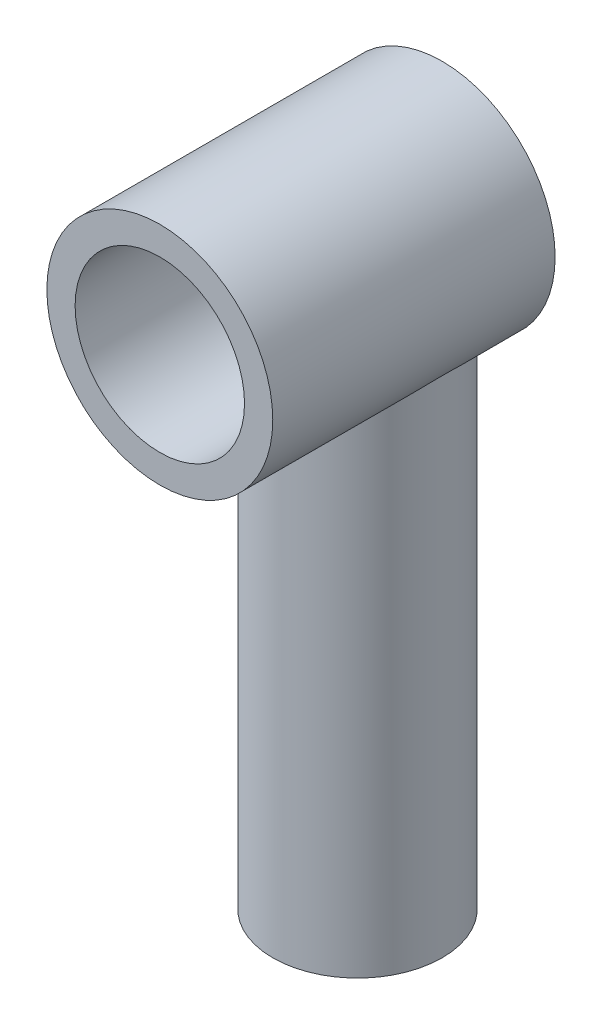
from build123d import *

# Parameters (mm, degrees)
ESQUISSE1_R             = 4
BOSS_EXTRU_1_DEPTH      = 8
BOSS_EXTRU_1_DEPTH_BACK = 2
ESQUISSE4_R             = 2
ENL_V_MAT_EXTRU_2_DEPTH = 18
BOSS_EXTRU_2_START      = -2.5
ESQUISSE3_R             = 3
ESQUISSE3_R_2           = 2
BOSS_EXTRU_2_DEPTH      = 1
BOSS_EXTRU_2_DEPTH_BACK = 18
ESQUISSE2_R             = 3
ENL_V_MAT_EXTRU_3_DEPTH = 9


with BuildPart() as part:
    # Esquisse1 → Boss.-Extru.1 (new body, two sides)
    with BuildSketch(Plane.XY) as boss_extru_1_sk:
        Circle(ESQUISSE1_R)
    extrude(amount=BOSS_EXTRU_1_DEPTH)
    extrude(boss_extru_1_sk.sketch, amount=-BOSS_EXTRU_1_DEPTH_BACK)

    # Esquisse4 → Enlèv. mat.-Extru.2 (cut)
    with BuildSketch(Plane(origin=(0, 0, 0), x_dir=(1, 0, 0), z_dir=(0, 1, 0))):
        with Locations((0, -1)):
            Circle(ESQUISSE4_R)
    extrude(amount=-ENL_V_MAT_EXTRU_2_DEPTH, mode=Mode.SUBTRACT)

    # Esquisse3 → Boss.-Extru.2 (add, two sides)
    with BuildSketch(Plane(origin=(0, 0, 0), x_dir=(1, 0, 0), z_dir=(0, 1, 0)).offset(BOSS_EXTRU_2_START)) as boss_extru_2_sk:
        with Locations((0, -1)):
            Circle(ESQUISSE3_R)
        with Locations((0, -1)):
            Circle(ESQUISSE3_R_2, mode=Mode.SUBTRACT)
    extrude(amount=BOSS_EXTRU_2_DEPTH)
    extrude(boss_extru_2_sk.sketch, amount=-BOSS_EXTRU_2_DEPTH_BACK)

    # Esquisse2 → Enlèv. mat.-Extru.3 (cut)
    with BuildSketch(Plane.XY.offset(8)):
        Circle(ESQUISSE2_R)
    extrude(amount=-ENL_V_MAT_EXTRU_3_DEPTH, mode=Mode.SUBTRACT)


solid = part.part
